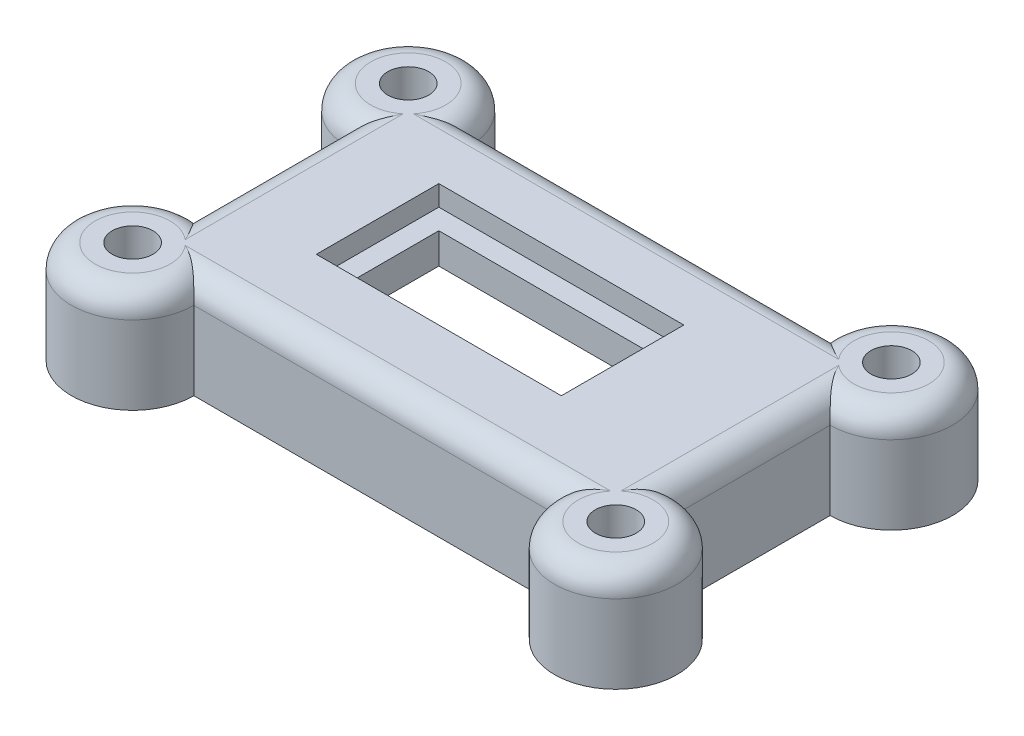
from build123d import *

# Parameters (mm, degrees)
BOSS_EXTRUDE1_DEPTH = 15
SKETCH2_4_W         = 49.5
SKETCH2_4_H         = 29.5
CUT_EXTRUDE1_DEPTH  = 7.5
SKETCH3_R           = 3
CUT_EXTRUDE2_DEPTH  = 6
SKETCH3_3_R         = 1.85
CUT_EXTRUDE3_DEPTH  = 16
SKETCH4_W           = 30
SKETCH4_H           = 12
CUT_EXTRUDE4_DEPTH  = 7.5
SKETCH4_3_W         = 36
SKETCH4_3_H         = 18
SKETCH4_3_W_2       = 30
SKETCH4_3_H_2       = 12
CUT_EXTRUDE5_DEPTH  = 3
FILLET2_R           = 3.5
SKETCH5_W           = 3
SKETCH5_H           = 30
CUT_EXTRUDE6_DEPTH  = 1.5


with BuildPart() as part:
    # Sketch2 → Boss-Extrude1 (new body)
    with BuildSketch(Plane(origin=(0, 0, 0), x_dir=(1, 0, 0), z_dir=(0, 1, 0))):
        with BuildLine():
            Line((9, 0), (62, 0))
            ThreePointArc((62, 0), (77.363961031, -6.363961031), (71, 9))
            Line((71, 9), (71, 31.5))
            ThreePointArc((71, 31.5), (77.363961031, 46.863961031), (62, 40.5))
            Line((62, 40.5), (9, 40.5))
            ThreePointArc((9, 40.5), (-6.363961031, 46.863961031), (0, 31.5))
            Line((0, 31.5), (0, 9))
            ThreePointArc((0, 9), (-6.363961031, -6.363961031), (9, 0))
        make_face()
    extrude(amount=BOSS_EXTRUDE1_DEPTH)

    # Sketch2_4 → Cut-Extrude1 (cut)
    with BuildSketch(Plane(origin=(0, 0, 0), x_dir=(1, 0, 0), z_dir=(0, 1, 0))):
        with Locations((32.75, 20.25)):
            Rectangle(SKETCH2_4_W, SKETCH2_4_H)
    extrude(amount=CUT_EXTRUDE1_DEPTH, mode=Mode.SUBTRACT)

    # Sketch3 → Cut-Extrude2 (cut)
    with BuildSketch(Plane(origin=(0, 15, 0), x_dir=(1, 0, 0), z_dir=(0, 1, 0))):
        Circle(SKETCH3_R)
        with Locations((0, 40.5)):
            Circle(SKETCH3_R)
        with Locations((71, 40.5)):
            Circle(SKETCH3_R)
        with Locations((71, 0)):
            Circle(SKETCH3_R)
    extrude(amount=-CUT_EXTRUDE2_DEPTH, mode=Mode.SUBTRACT)

    # Sketch3_3 → Cut-Extrude3 (cut, through all)
    with BuildSketch(Plane(origin=(0, 15, 0), x_dir=(1, 0, 0), z_dir=(0, 1, 0))):
        Circle(SKETCH3_3_R)
        with Locations((0, 40.5)):
            Circle(SKETCH3_3_R)
        with Locations((71, 40.5)):
            Circle(SKETCH3_3_R)
        with Locations((71, 0)):
            Circle(SKETCH3_3_R)
    extrude(amount=-CUT_EXTRUDE3_DEPTH, mode=Mode.SUBTRACT)

    # Sketch4 → Cut-Extrude4 (cut)
    with BuildSketch(Plane(origin=(0, 15, 0), x_dir=(1, 0, 0), z_dir=(0, 1, 0))):
        with Locations((33, 21)):
            Rectangle(SKETCH4_W, SKETCH4_H)
    extrude(amount=-CUT_EXTRUDE4_DEPTH, mode=Mode.SUBTRACT)

    # Sketch4_3 → Cut-Extrude5 (cut)
    with BuildSketch(Plane(origin=(0, 15, 0), x_dir=(1, 0, 0), z_dir=(0, 1, 0))):
        with Locations((33, 21)):
            Rectangle(SKETCH4_3_W, SKETCH4_3_H)
        with Locations((33, 21)):
            Rectangle(SKETCH4_3_W_2, SKETCH4_3_H_2, mode=Mode.SUBTRACT)
    extrude(amount=-CUT_EXTRUDE5_DEPTH, mode=Mode.SUBTRACT)

    # Fillet2
    fillet2_edges = [part.edges().sort_by_distance(p)[0] for p in [
        (77.363961031, 15, 6.363961031),
        (71, 15, -20.25),
        (77.363961031, 15, -46.863961031),
        (35.5, 15, -40.5),
        (-6.363961031, 15, -46.863961031),
        (0, 15, -20.25),
        (-6.363961031, 15, 6.363961031),
        (35.5, 15, 0),
    ]]
    fillet(fillet2_edges, radius=FILLET2_R)

    # Sketch5 → Cut-Extrude6 (cut)
    with BuildSketch(Plane.XZ):
        with Locations((66.5, -22)):
            Rectangle(SKETCH5_W, SKETCH5_H)
    extrude(amount=-CUT_EXTRUDE6_DEPTH, mode=Mode.SUBTRACT)


solid = part.part
